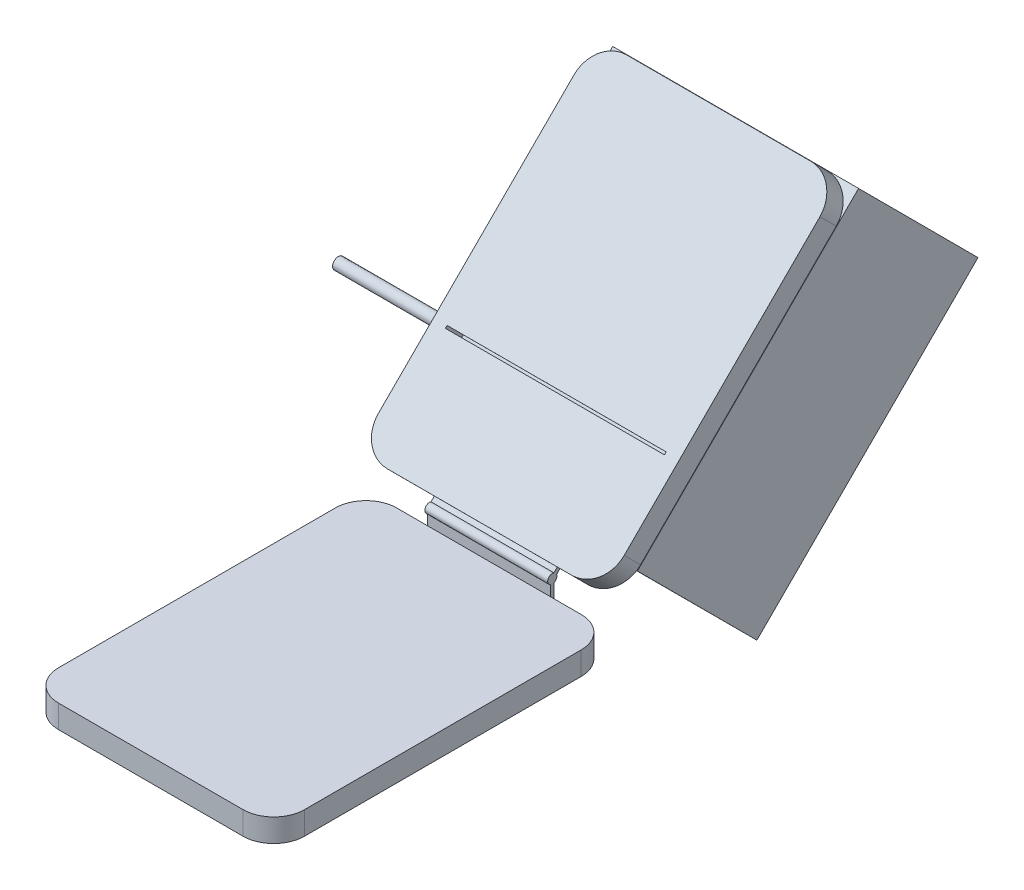
from build123d import *

# Parameters (mm, degrees)
SKETCH1_W            = 16
SKETCH1_H            = 1.5
BOSS_EXTRUDE1_DEPTH  = 22
FILLET1_R            = 2
SKETCH2_W            = 8
SKETCH2_H            = 2
BOSS_EXTRUDE2_DEPTH  = 0.25
SKETCH3_R            = 0.375
BOSS_EXTRUDE3_DEPTH  = 0.15
SKETCH4_R            = 0.3
BOSS_EXTRUDE4_DEPTH  = 8
BOSS_EXTRUDE5_DEPTH  = 8
SKETCH6_R            = 0.375
BOSS_EXTRUDE6_DEPTH  = 0.15
SKETCH7_W            = 16
SKETCH7_H            = 1.5
BOSS_EXTRUDE7_DEPTH  = 1.5
BOSS_EXTRUDE8_DEPTH  = 20.5
FILLET2_R            = 2
SKETCH9_W            = 14.259338364
SKETCH9_H            = 0.156424717
CUT_EXTRUDE1_DEPTH   = 20.5
SKETCH10_W           = 16
SKETCH10_H           = 20.335857824
SKETCH10_W_2         = 13.907599839
SKETCH10_H_2         = 18.335857824
BOSS_EXTRUDE9_DEPTH  = 10
SKETCH11_W           = 16
SKETCH11_H           = 20.335857824
BOSS_EXTRUDE10_DEPTH = 1
CUT_EXTRUDE2_DEPTH   = 11
SKETCH13_R           = 0.375
BOSS_EXTRUDE11_DEPTH = 25


with BuildPart() as part:
    # Sketch1 → Boss-Extrude1 (new body)
    with BuildSketch(Plane.XY):
        Rectangle(SKETCH1_W, SKETCH1_H)
    extrude(amount=BOSS_EXTRUDE1_DEPTH)

    # Fillet1
    fillet1_edges = [part.edges().sort_by_distance(p)[0] for p in [
        (-8, 0, 22),
        (8, 0, 22),
        (-8, 0, 0),
        (8, 0, 0),
    ]]
    fillet(fillet1_edges, radius=FILLET1_R)

    # Sketch2 → Boss-Extrude2 (add)
    with BuildSketch(Plane(origin=(0, 0, 0), x_dir=(-1, 0, 0), z_dir=(0, 0, -1))):
        with Locations((0, 0.5)):
            Rectangle(SKETCH2_W, SKETCH2_H)
    extrude(amount=BOSS_EXTRUDE2_DEPTH)

    # Sketch3 → Boss-Extrude3 (add)
    with BuildSketch(Plane(origin=(0, 0, -0.25), x_dir=(-1, 0, 0), z_dir=(0, 0, -1))):
        with Locations((-3, 0.5)):
            Circle(SKETCH3_R)
        Polygon((-3.05, 0.551330007), (-3.05, 0.800158256), (-2.95, 0.800158256), (-2.95, 0.551330007), (-2.7, 0.551330007), (-2.7, 0.45), (-2.95, 0.45), (-2.95, 0.2), (-3.05, 0.2), (-3.05, 0.45), (-3.3, 0.45), (-3.3, 0.551330007), align=None, mode=Mode.SUBTRACT)
        with Locations((0, 0.5)):
            Circle(SKETCH3_R)
        Polygon((-0.05, 0.2), (-0.05, 0.45), (-0.3, 0.45), (-0.3, 0.551330007), (-0.05, 0.551330007), (-0.05, 0.800158256), (0.05, 0.800158256), (0.05, 0.551330007), (0.3, 0.551330007), (0.3, 0.45), (0.05, 0.45), (0.05, 0.2), align=None, mode=Mode.SUBTRACT)
        with Locations((3, 0.5)):
            Circle(SKETCH3_R)
        Polygon((2.95, 0.2), (2.95, 0.45), (2.7, 0.45), (2.7, 0.551330007), (2.95, 0.551330007), (2.95, 0.800158256), (3.05, 0.800158256), (3.05, 0.551330007), (3.3, 0.551330007), (3.3, 0.45), (3.05, 0.45), (3.05, 0.2), align=None, mode=Mode.SUBTRACT)
    extrude(amount=BOSS_EXTRUDE3_DEPTH)

    # Sketch4 → Boss-Extrude4 (add)
    with BuildSketch(Plane(origin=(4, 0, 0), x_dir=(0, 0, -1), z_dir=(1, 0, 0))):
        with Locations((0.125, 1.7)):
            Circle(SKETCH4_R)
    extrude(amount=-BOSS_EXTRUDE4_DEPTH)

    # Sketch5 → Boss-Extrude5 (add)
    with BuildSketch(Plane(origin=(4, 0, 0), x_dir=(0, 0, -1), z_dir=(1, 0, 0))):
        Polygon((1.595306779, 3.344927555), (1.771017264, 3.168973693), (0.348913537, 1.749477894), (0.173440849, 1.924950583), align=None)
    extrude(amount=-BOSS_EXTRUDE5_DEPTH)

    # Sketch6 → Boss-Extrude6 (add)
    with BuildSketch(Plane(origin=(0, 0.701888086, 0.700600926), x_dir=(-1, 0, 0), z_dir=(0, -0.707755443, -0.706457524))):
        with Locations((3, 2.491187613)):
            Circle(SKETCH6_R)
        Polygon((2.95, 2.541187613), (2.95, 2.791187613), (3.05, 2.791187613), (3.05, 2.541187613), (3.3, 2.541187613), (3.3, 2.441187613), (3.05, 2.441187613), (3.05, 2.191187613), (2.95, 2.191187613), (2.95, 2.441187613), (2.7, 2.441187613), (2.7, 2.541187613), align=None, mode=Mode.SUBTRACT)
        with Locations((0, 2.491187613)):
            Circle(SKETCH6_R)
        Polygon((0.05, 2.441187613), (0.05, 2.191187613), (-0.05, 2.191187613), (-0.05, 2.441187613), (-0.3, 2.441187613), (-0.3, 2.541187613), (-0.05, 2.541187613), (-0.05, 2.791187613), (0.05, 2.791187613), (0.05, 2.541187613), (0.3, 2.541187613), (0.3, 2.441187613), align=None, mode=Mode.SUBTRACT)
        with Locations((-3, 2.491187613)):
            Circle(SKETCH6_R)
        Polygon((-2.95, 2.441187613), (-2.95, 2.191187613), (-3.05, 2.191187613), (-3.05, 2.441187613), (-3.3, 2.441187613), (-3.3, 2.541187613), (-3.05, 2.541187613), (-3.05, 2.791187613), (-2.95, 2.791187613), (-2.95, 2.541187613), (-2.7, 2.541187613), (-2.7, 2.441187613), align=None, mode=Mode.SUBTRACT)
    extrude(amount=BOSS_EXTRUDE6_DEPTH)

    # Sketch7 → Boss-Extrude7 (add)
    with BuildSketch(Plane(origin=(0, 0.877034448, 0.875869302), x_dir=(1, 0, 0), z_dir=(0, 0.707576635, 0.706636615))):
        with Locations((0, 2.622450086)):
            Rectangle(SKETCH7_W, SKETCH7_H)
    extrude(amount=BOSS_EXTRUDE7_DEPTH)

    # Sketch8 → Boss-Extrude8 (add)
    with BuildSketch(Plane(origin=(0, 2.383096713, -2.386266884), x_dir=(-1, 0, 0), z_dir=(0, 0.706636615, -0.707576635))):
        Polygon((-8, 1.239490402), (-4, 1.239490402), (4, 1.239490402), (8, 1.239490402), (8, 2.739490402), (-8, 2.739490402), align=None)
    extrude(amount=BOSS_EXTRUDE8_DEPTH)

    # Fillet2
    fillet2_edges = [part.edges().sort_by_distance(p)[0] for p in [
        (8, 2.730858715, 0.080944831),
        (-8, 2.730858715, 0.080944831),
        (8, 18.276864241, -15.485741141),
        (-8, 18.276864241, -15.485741141),
    ]]
    fillet(fillet2_edges, radius=FILLET2_R)

    # Sketch9 → Cut-Extrude1 (cut)
    with BuildSketch(Plane(origin=(0, 1.938399401, 1.935824224), x_dir=(1, 0, 0), z_dir=(0, 0.707576635, 0.706636615))):
        with Locations((0, 8.883775495)):
            Rectangle(SKETCH9_W, SKETCH9_H)
    extrude(amount=-CUT_EXTRUDE1_DEPTH, mode=Mode.SUBTRACT)

    # Sketch10 → Boss-Extrude9 (add)
    with BuildSketch(Plane(origin=(0, 0.877034448, 0.875869302), x_dir=(-1, 0, 0), z_dir=(0, -0.707576635, -0.706636615))):
        with Locations((-0.025561506, 13.721643007)):
            Rectangle(SKETCH10_W, SKETCH10_H)
        with Locations((-0.071761587, 13.721643007)):
            Rectangle(SKETCH10_W_2, SKETCH10_H_2, mode=Mode.SUBTRACT)
    extrude(amount=BOSS_EXTRUDE9_DEPTH)

    # Sketch11 → Boss-Extrude10 (add)
    with BuildSketch(Plane(origin=(0, -6.198731903, -6.190496846), x_dir=(-1, 0, 0), z_dir=(0, -0.707576635, -0.706636615))):
        with Locations((-0.025561506, 13.721643007)):
            Rectangle(SKETCH11_W, SKETCH11_H)
    extrude(amount=BOSS_EXTRUDE10_DEPTH)

    # Sketch12 → Cut-Extrude2 (cut)
    with BuildSketch(Plane.ZY.offset(7.974438494)):
        Polygon((-5.194715869, 6.939554806), (-11.745034119, 0.380522838), (-12.264104898, 0.898904028), (-5.713786648, 7.457935996), align=None)
    extrude(amount=-CUT_EXTRUDE2_DEPTH, mode=Mode.SUBTRACT)

    # Sketch13 → Boss-Extrude11 (add)
    with BuildSketch(Plane.ZY.offset(-8.025561506)):
        with Locations((-7.173250291, 5.474563224)):
            Circle(SKETCH13_R)
    extrude(amount=BOSS_EXTRUDE11_DEPTH)


solid = part.part
